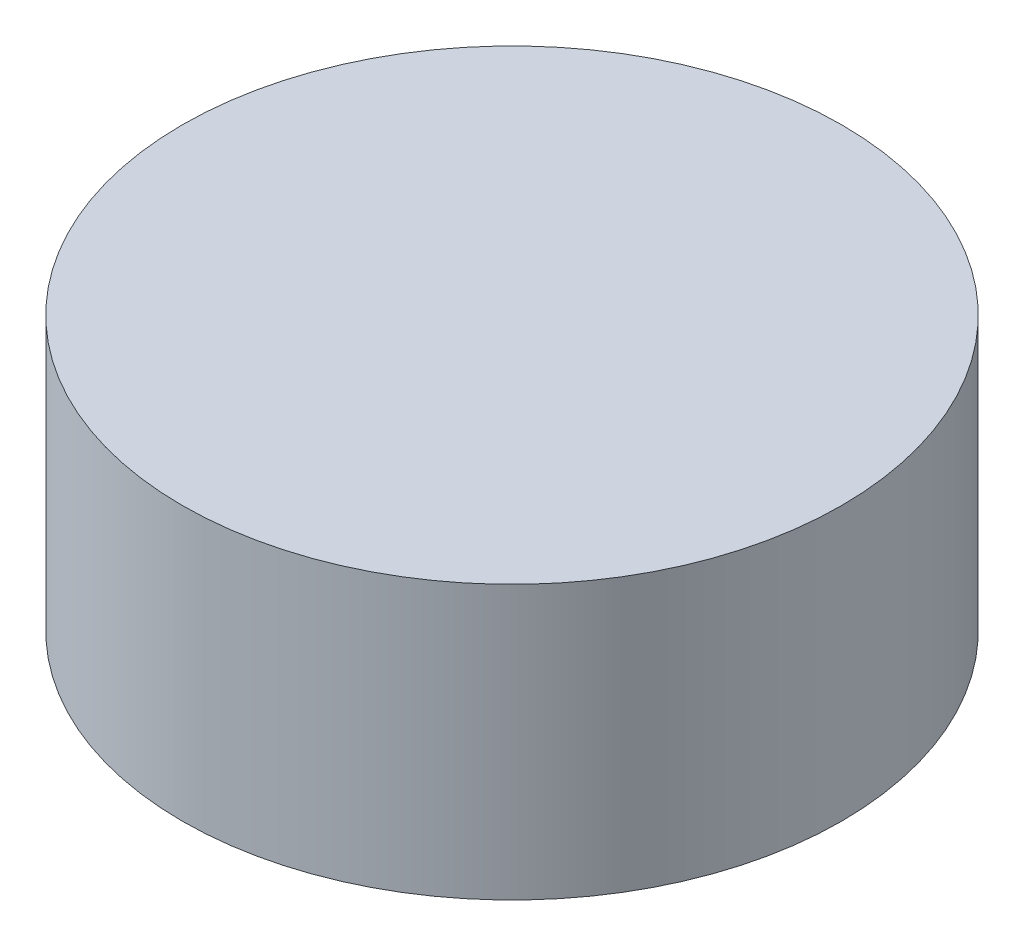
from build123d import *

# Parameters (mm, degrees)
SKETCH1_R           = 20.5
BOSS_EXTRUDE1_DEPTH = 17


with BuildPart() as part:
    # Sketch1 → Boss-Extrude1 (new body)
    with BuildSketch(Plane(origin=(0, 0, 0), x_dir=(1, 0, 0), z_dir=(0, 1, 0))):
        Circle(SKETCH1_R)
    extrude(amount=BOSS_EXTRUDE1_DEPTH)


solid = part.part
